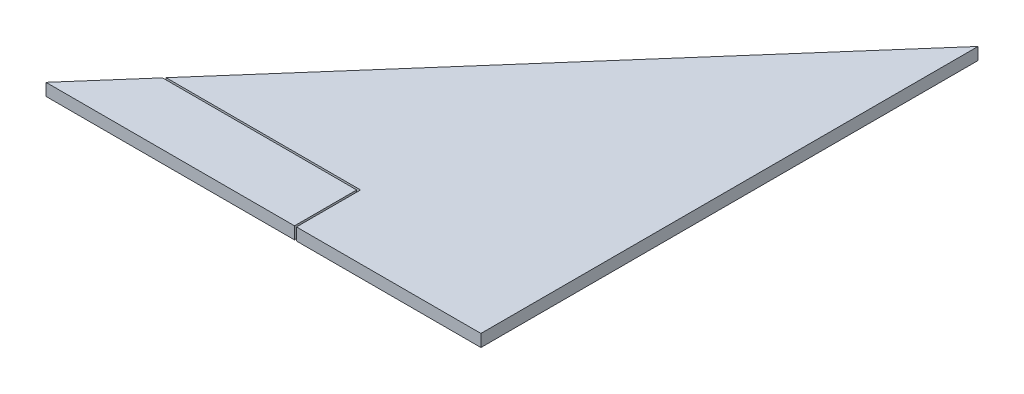
from build123d import *

# Parameters (mm, degrees)
BOSS_EXTRUDE1_DEPTH     = 5
CUT_EXTRUDE_THIN1_DEPTH = 6


with BuildPart() as part:
    # Sketch1 → Boss-Extrude1 (new body)
    with BuildSketch(Plane(origin=(0, 0, 0), x_dir=(1, 0, 0), z_dir=(0, 1, 0))):
        Polygon((0, 0), (0, 203.2), (-177.8, 0), align=None)
    extrude(amount=BOSS_EXTRUDE1_DEPTH)

    # Sketch1_3 → Cut-Extrude-Thin1 (cut)
    with BuildSketch(Plane(origin=(0, 0, 0), x_dir=(1, 0, 0), z_dir=(0, 1, 0))):
        Polygon((-76.2, 0), (-76.2, 25.4), (-155.575, 25.4), (-155.575, 26.19375), (-75.40625, 26.19375), (-75.40625, 0), align=None)
    extrude(amount=CUT_EXTRUDE_THIN1_DEPTH, mode=Mode.SUBTRACT)


with BuildPart() as cut_extrude_thin1_piece_1:
    # of the separate pieces the step leaves, piece 1, a body of its own (cut_extrude_thin1_pieces)
    add(part.part.solids().sort_by_distance((0, 0, 0))[0])


with BuildPart() as cut_extrude_thin1_piece_2:
    # of the separate pieces the step leaves, piece 2, a body of its own (cut_extrude_thin1_pieces)
    add(part.part.solids().sort_by_distance((-177.8, 0, 0))[0])


solid = Compound([cut_extrude_thin1_piece_1.part, cut_extrude_thin1_piece_2.part])
